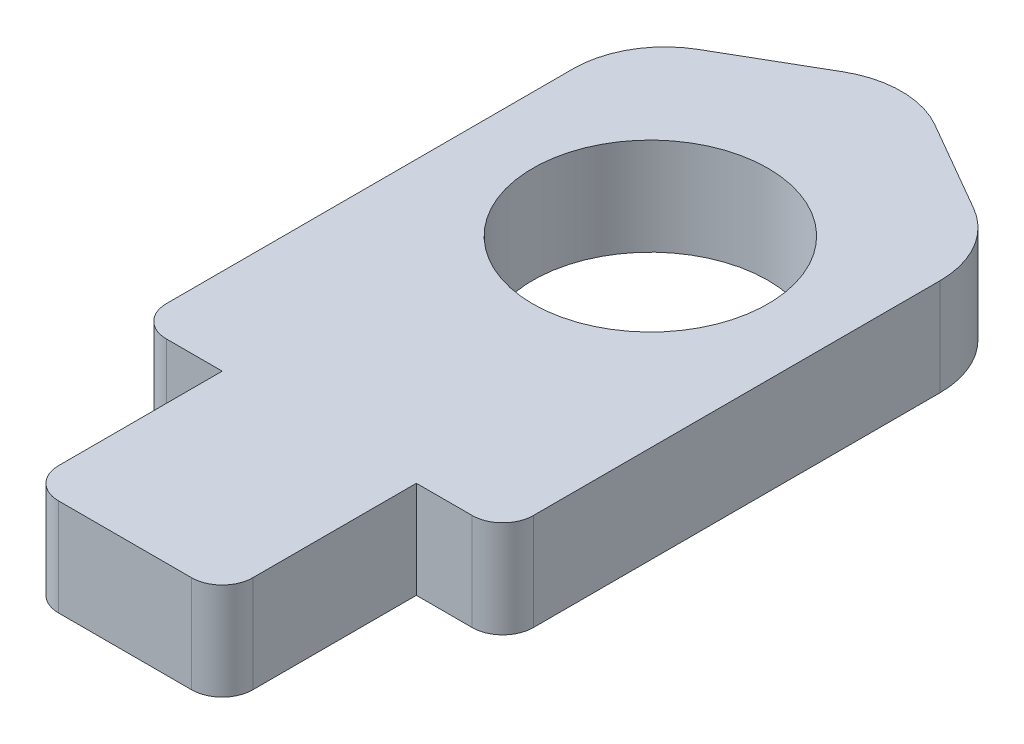
from build123d import *

# Parameters (mm, degrees)
SKETCH2_R                 = 3.845
MOTORMOUNT_EXTRUDE_DEPTH  = 3.175
MOTORMOUNT_CORNERFILLET_R = 1


with BuildPart() as part:
    # Sketch2 → MotorMount_Extrude (new body)
    with BuildSketch(Plane(origin=(0, 0, 0), x_dir=(1, 0, 0), z_dir=(0, 1, 0))):
        with BuildLine():
            Line((-6, 3.472949192), (-6, -10.8257274))
            Line((-6, -10.8257274), (-3.175, -10.8257274))
            Line((-3.175, -10.8257274), (-3.175, -17.1757274))
            Line((-3.175, -17.1757274), (3.175, -17.1757274))
            Line((3.175, -17.1757274), (3.175, -10.8257274))
            Line((3.175, -10.8257274), (6, -10.8257274))
            Line((6, -10.8257274), (6, 3.472949192))
            ThreePointArc((6, 3.472949192), (5.598076211, 4.972949192), (4.5, 6.071025404))
            Line((4.5, 6.071025404), (1.5, 7.803076211))
            ThreePointArc((1.5, 7.803076211), (0, 8.205), (-1.5, 7.803076211))
            Line((-1.5, 7.803076211), (-4.5, 6.071025404))
            ThreePointArc((-4.5, 6.071025404), (-5.598076211, 4.972949192), (-6, 3.472949192))
        make_face()
        Circle(SKETCH2_R, mode=Mode.SUBTRACT)
    extrude(amount=MOTORMOUNT_EXTRUDE_DEPTH)

    # MotorMount_CornerFillet
    motormount_cornerfillet_edges = [part.edges().sort_by_distance(p)[0] for p in [
        (6, 1.5875, 10.8257274),
        (3.175, 1.5875, 17.1757274),
        (-3.175, 1.5875, 17.1757274),
        (-6, 1.5875, 10.8257274),
    ]]
    fillet(motormount_cornerfillet_edges, radius=MOTORMOUNT_CORNERFILLET_R)


solid = part.part
